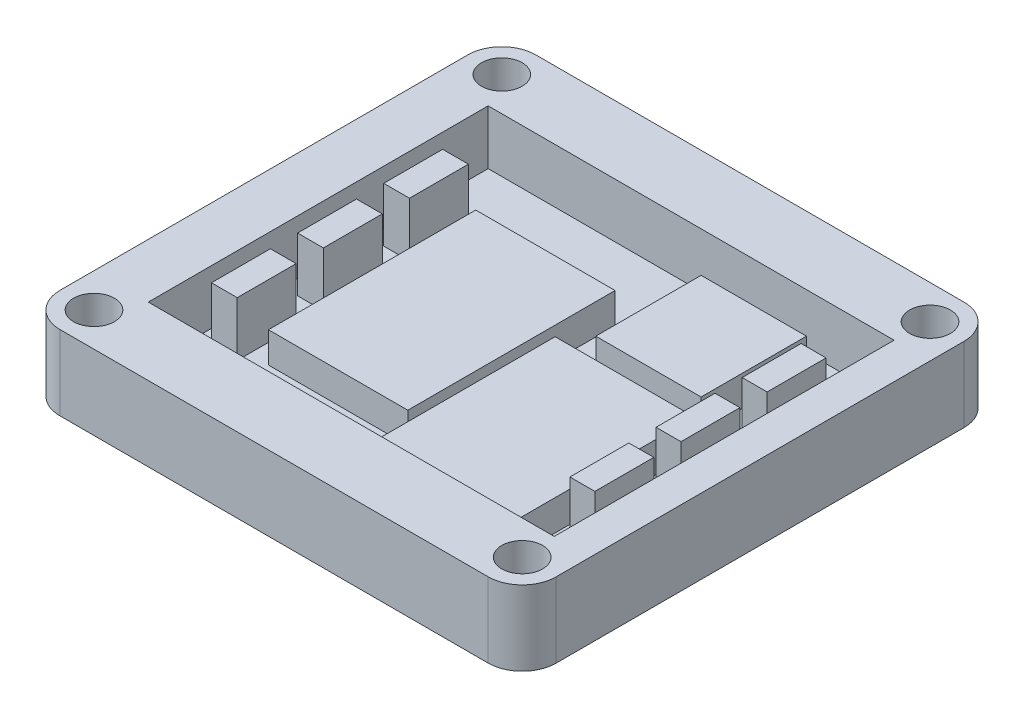
from build123d import *

# Parameters (mm, degrees)
SKETCH2_R             = 3
BOSS_EXTRUDE1_DEPTH   = 25
SKETCH5_W             = 200
SKETCH5_H             = 50
CUT_EXTRUDE1_DEPTH    = 8
SKETCH9_W             = 20.5
SKETCH9_H             = 26.5
BATTERY_DEPTH         = 4.5
SKETCH8_W             = 15.5
SKETCH8_H             = 15.5
TEG_TOP_MIDDLE_DEPTH  = 4.5
SKETCH10_W            = 20.5
SKETCH10_H            = 30.5
POWPCB_NEXTBATT_DEPTH = 4.5
SKETCH12_W            = 247.875067181
SKETCH12_H            = 102.432022038
CUT_EXTRUDE2_DEPTH    = 14
SKETCH13_W            = 7.9930444
SKETCH13_H            = 8
SKETCH13_W_2          = 5.289616262
BOSS_EXTRUDE2_DEPTH   = 51
SKETCH14_W            = 3.79
SKETCH14_H            = 8.67
BOSS_EXTRUDE3_DEPTH   = 8
SKETCH15_W            = 3.67
SKETCH15_H            = 8.67
BOSS_EXTRUDE4_DEPTH   = 9


with BuildPart() as part:
    # Sketch2 → Boss-Extrude1 (new body)
    with BuildSketch(Plane(origin=(0, 0, 0), x_dir=(1, 0, 0), z_dir=(0, 1, 0))):
        with BuildLine():
            Line((-31.5, -35), (31.5, -35))
            ThreePointArc((31.5, -35), (35.035533906, -33.535533906), (36.5, -30))
            Line((36.5, -30), (36.5, 30))
            ThreePointArc((36.5, 30), (35.035533906, 33.535533906), (31.5, 35))
            Line((31.5, 35), (-31.5, 35))
            ThreePointArc((-31.5, 35), (-35.035533906, 33.535533906), (-36.5, 30))
            Line((-36.5, 30), (-36.5, -30))
            ThreePointArc((-36.5, -30), (-35.035533906, -33.535533906), (-31.5, -35))
        make_face()
        with Locations((-31.5, 30)):
            Circle(SKETCH2_R, mode=Mode.SUBTRACT)
        with Locations((-31.5, -30)):
            Circle(SKETCH2_R, mode=Mode.SUBTRACT)
        with Locations((31.5, 30)):
            Circle(SKETCH2_R, mode=Mode.SUBTRACT)
        with Locations((31.5, -30)):
            Circle(SKETCH2_R, mode=Mode.SUBTRACT)
    extrude(amount=BOSS_EXTRUDE1_DEPTH)

    # Sketch5 → Cut-Extrude1 (cut)
    with BuildSketch(Plane(origin=(0, 25, 0), x_dir=(1, 0, 0), z_dir=(0, 1, 0))):
        Rectangle(SKETCH5_W, SKETCH5_H)
    extrude(amount=-CUT_EXTRUDE1_DEPTH, mode=Mode.SUBTRACT)

    # Sketch9 → Battery (add)
    with BuildSketch(Plane(origin=(78.136647367, 17, 0), x_dir=(1, 0, 0), z_dir=(0, 1, 0))):
        with Locations((-65.5549825, -9.238518767)):
            Rectangle(SKETCH9_W, SKETCH9_H)
    extrude(amount=BATTERY_DEPTH)

    # Sketch8 → TEG(Top Middle) (add)
    with BuildSketch(Plane(origin=(0.095109107, 17, -16.130780733), x_dir=(1, 0, 0), z_dir=(0, 1, 0))):
        with Locations((12.905058884, -1.308244326)):
            Rectangle(SKETCH8_W, SKETCH8_H)
    extrude(amount=TEG_TOP_MIDDLE_DEPTH)

    # Sketch10 → PowPCB(nextbatt) (add)
    with BuildSketch(Plane(origin=(-57.874767331, 17, 5.938113267), x_dir=(1, 0, 0), z_dir=(0, 1, 0))):
        with Locations((48.479710494, 5)):
            Rectangle(SKETCH10_W, SKETCH10_H)
    extrude(amount=POWPCB_NEXTBATT_DEPTH)

    # Sketch12 → Cut-Extrude2 (cut)
    with BuildSketch(Plane.XZ):
        with Locations((-0.926975658, -6.36803857)):
            Rectangle(SKETCH12_W, SKETCH12_H)
    extrude(amount=-CUT_EXTRUDE2_DEPTH, mode=Mode.SUBTRACT)

    # Sketch13 → Boss-Extrude2 (add)
    with BuildSketch(Plane(origin=(0, 0, 25), x_dir=(-1, 0, 0), z_dir=(0, 0, -1))):
        with Locations((32.5034778, 21)):
            Rectangle(SKETCH13_W, SKETCH13_H)
        with Locations((-33.855191869, 21)):
            Rectangle(SKETCH13_W_2, SKETCH13_H)
    extrude(amount=BOSS_EXTRUDE2_DEPTH)

    # Sketch14 → Boss-Extrude3 (add)
    with BuildSketch(Plane(origin=(0, 17, 0), x_dir=(1, 0, 0), z_dir=(0, 1, 0))):
        with Locations((-24.424089145, -13.560130433)):
            Rectangle(SKETCH14_W, SKETCH14_H)
        with Locations((-24.424089145, 11.779869567)):
            Rectangle(SKETCH14_W, SKETCH14_H)
        with Locations((-24.424089145, -0.890130433)):
            Rectangle(SKETCH14_W, SKETCH14_H)
    extrude(amount=BOSS_EXTRUDE3_DEPTH)

    # Sketch15 → Boss-Extrude4 (add)
    with BuildSketch(Plane(origin=(49.484284455, 25, 12.830577775), x_dir=(1, 0, 0), z_dir=(0, 1, 0))):
        with Locations((-22.856133, 0.894138312)):
            Rectangle(SKETCH15_W, SKETCH15_H)
        with Locations((-22.856133, 26.234138312)):
            Rectangle(SKETCH15_W, SKETCH15_H)
        with Locations((-22.856133, 13.564138312)):
            Rectangle(SKETCH15_W, SKETCH15_H)
    extrude(amount=-BOSS_EXTRUDE4_DEPTH)


solid = part.part
